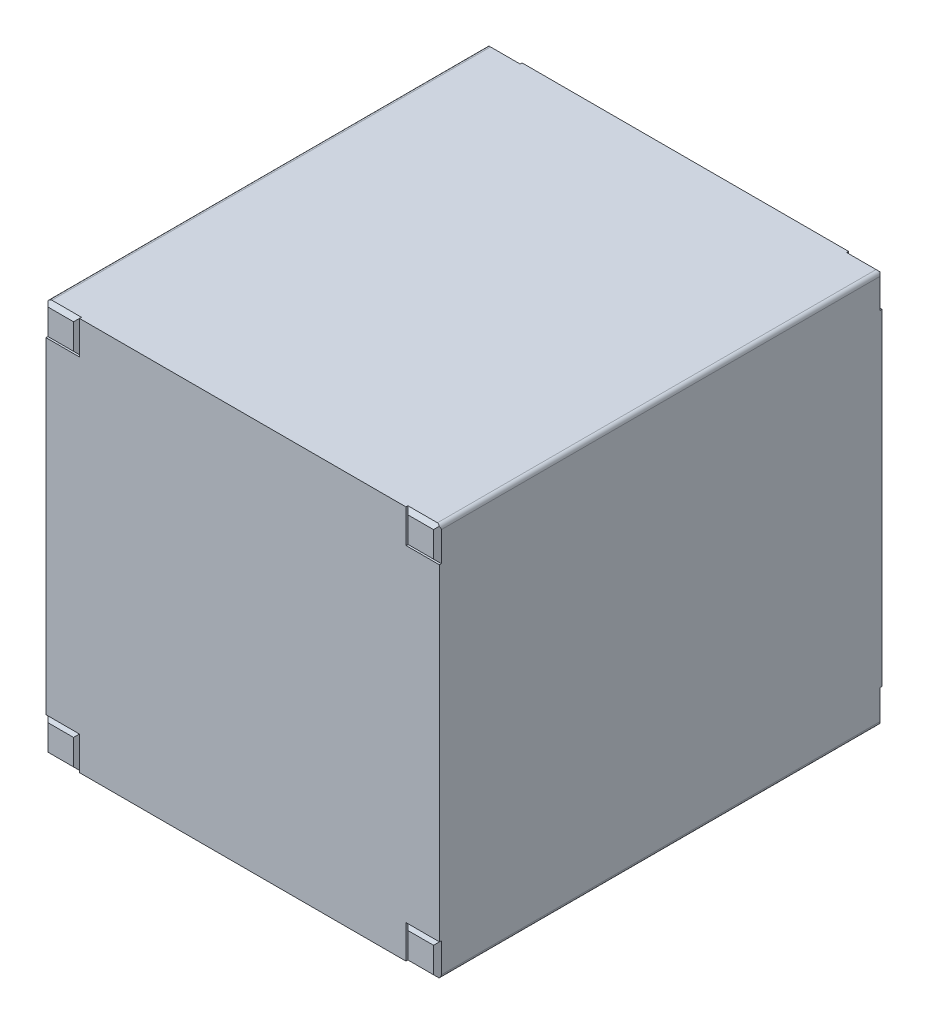
from build123d import *

# Parameters (mm, degrees)
BOSS_EXTRUDE1_DEPTH        = 56.75
BOSS_EXTRUDE1_DEPTH_BACK   = 56.75
SKETCH1_W                  = 8.5
SKETCH1_H                  = 8.5
BOSS_EXTRUDE1_2_DEPTH      = 56.75
BOSS_EXTRUDE1_2_DEPTH_BACK = 56.75
BOSS_EXTRUDE1_3_DEPTH      = 56.75
BOSS_EXTRUDE1_3_DEPTH_BACK = 56.75
BOSS_EXTRUDE1_4_DEPTH      = 56.75
BOSS_EXTRUDE1_4_DEPTH_BACK = 56.75
BOSS_EXTRUDE2_DEPTH        = 50.25
BOSS_EXTRUDE2_DEPTH_BACK   = 50.25
SKETCH2_W                  = 100
SKETCH2_H                  = 100
CHAMFER2_SIZE              = 1
FILLET1_R                  = 1
BOSS_EXTRUDE3_DEPTH        = 6


with BuildPart() as part:
    # Sketch1 → Boss-Extrude1 (new, two sides: drawn at the far end of the back side and taken through both)
    with BuildSketch(Plane.XY.offset(-BOSS_EXTRUDE1_DEPTH_BACK)):
        with Locations((-45.75, 45.75)):
            Rectangle(SKETCH1_W, SKETCH1_H)
    extrude(amount=BOSS_EXTRUDE1_DEPTH + BOSS_EXTRUDE1_DEPTH_BACK)



with BuildPart() as body_2:
    # Sketch1 → Boss-Extrude1 2 (new, two sides: drawn at the far end of the back side and taken through both)
    with BuildSketch(Plane.XY.offset(-BOSS_EXTRUDE1_2_DEPTH_BACK)):
        with Locations((45.75, 45.75)):
            Rectangle(SKETCH1_W, SKETCH1_H)
    extrude(amount=BOSS_EXTRUDE1_2_DEPTH + BOSS_EXTRUDE1_2_DEPTH_BACK)


with BuildPart() as body_3:
    # Sketch1 → Boss-Extrude1 3 (new, two sides: drawn at the far end of the back side and taken through both)
    with BuildSketch(Plane.XY.offset(-BOSS_EXTRUDE1_3_DEPTH_BACK)):
        with Locations((45.75, -45.75)):
            Rectangle(SKETCH1_W, SKETCH1_H)
    extrude(amount=BOSS_EXTRUDE1_3_DEPTH + BOSS_EXTRUDE1_3_DEPTH_BACK)


with BuildPart() as body_4:
    # Sketch1 → Boss-Extrude1 4 (new, two sides: drawn at the far end of the back side and taken through both)
    with BuildSketch(Plane.XY.offset(-BOSS_EXTRUDE1_4_DEPTH_BACK)):
        with Locations((-45.75, -45.75)):
            Rectangle(SKETCH1_W, SKETCH1_H)
    extrude(amount=BOSS_EXTRUDE1_4_DEPTH + BOSS_EXTRUDE1_4_DEPTH_BACK)


with BuildPart() as part_1:
    add(part.part)

    add(body_2.part)  # Boss-Extrude2 merges body 2

    add(body_3.part)  # Boss-Extrude2 merges body 3

    add(body_4.part)  # Boss-Extrude2 merges body 4
    # Sketch2 → Boss-Extrude2 (add, two sides: drawn at the far end of the back side and taken through both)
    with BuildSketch(Plane.XY.offset(-BOSS_EXTRUDE2_DEPTH_BACK)):
        Rectangle(SKETCH2_W, SKETCH2_H)
    extrude(amount=BOSS_EXTRUDE2_DEPTH + BOSS_EXTRUDE2_DEPTH_BACK)

    # Chamfer2
    chamfer2_edges = [part_1.edges().sort_by_distance(p)[0] for p in [
        (-45.75, -41.5, 56.75),
        (-41.5, -45.75, 56.75),
        (-45.75, -50, 56.75),
        (-50, -45.75, 56.75),
        (41.5, -45.75, 56.75),
        (45.75, -41.5, 56.75),
        (50, -45.75, 56.75),
        (45.75, -50, 56.75),
        (45.75, 41.5, 56.75),
        (41.5, 45.75, 56.75),
        (45.75, 50, 56.75),
        (50, 45.75, 56.75),
        (-41.5, 45.75, 56.75),
        (-45.75, 41.5, 56.75),
        (-50, 45.75, 56.75),
        (-45.75, 50, 56.75),
        (41.5, 45.75, -56.75),
        (45.75, 41.5, -56.75),
        (50, 45.75, -56.75),
        (45.75, 50, -56.75),
        (-45.75, 41.5, -56.75),
        (-41.5, 45.75, -56.75),
        (-45.75, 50, -56.75),
        (-50, 45.75, -56.75),
        (-41.5, -45.75, -56.75),
        (-45.75, -41.5, -56.75),
        (-50, -45.75, -56.75),
        (-45.75, -50, -56.75),
        (45.75, -41.5, -56.75),
        (41.5, -45.75, -56.75),
        (45.75, -50, -56.75),
        (50, -45.75, -56.75),
    ]]
    chamfer(chamfer2_edges, length=CHAMFER2_SIZE)

    # Fillet1
    fillet1_edges = [part_1.edges().sort_by_distance(p)[0] for p in [
        (50, -50, 0),
        (-50, -50, 0),
        (-50, 50, 0),
        (50, 50, 0),
    ]]
    fillet(fillet1_edges, radius=FILLET1_R)

    # Sketch3 → Boss-Extrude3 (add)
    with BuildSketch(Plane.XY.offset(50.25)):
        Polygon((-41.5, 50), (41.5, 50), (41.5, 41.5), (50, 41.5), (50, -41.5), (41.5, -41.5), (41.5, -50), (-41.5, -50), (-41.5, -41.5), (-50, -41.5), (-50, 41.5), (-41.5, 41.5), align=None)
    boss_extrude3 = extrude(amount=BOSS_EXTRUDE3_DEPTH)

    # Mirror1: Boss-Extrude3 across plane
    add(boss_extrude3.mirror(Plane.XY))


solid = part_1.part
